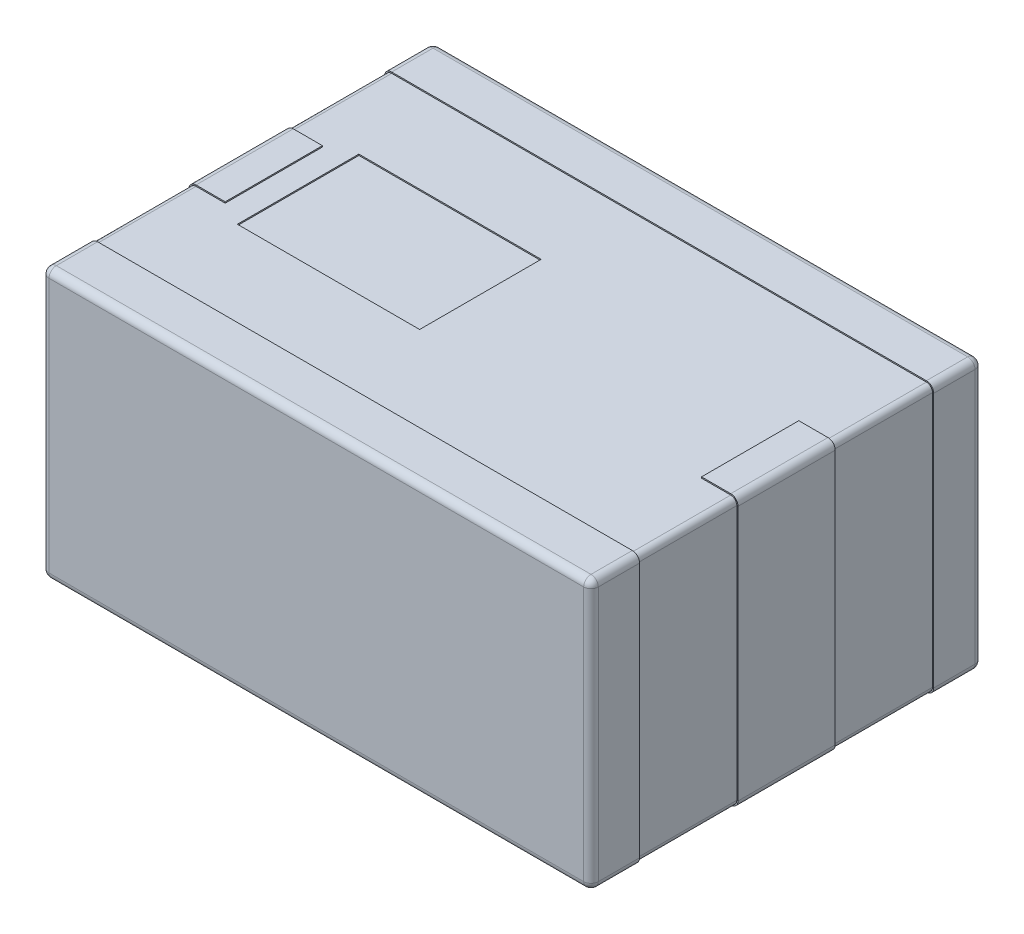
from build123d import *

# Parameters (mm, degrees)
SKETCH1_W           = 4.5
SKETCH1_H           = 3.2
BOSS_EXTRUDE1_DEPTH = 2.2
FILLET1_R           = 0.05
SKETCH2_W           = 0.3
SKETCH2_H           = 0.8
SKETCH2_W_2         = 4.52
SKETCH2_H_2         = 0.4
BOSS_EXTRUDE2_DEPTH = 0.01
SKETCH4_W           = 0.3
SKETCH4_H           = 0.8
SKETCH4_W_2         = 4.52
SKETCH4_H_2         = 0.4
BOSS_EXTRUDE3_DEPTH = 2.21
SKETCH3_W           = 1.5
SKETCH3_H           = 1
CUT_EXTRUDE1_DEPTH  = 0.01
FILLET2_R           = 0.06


with BuildPart() as part:
    # Sketch1 → Boss-Extrude1 (new body)
    with BuildSketch(Plane(origin=(0, 0, 0), x_dir=(1, 0, 0), z_dir=(0, 1, 0))):
        Rectangle(SKETCH1_W, SKETCH1_H)
    extrude(amount=BOSS_EXTRUDE1_DEPTH)

    # Fillet1
    fillet1_edges = [part.edges().sort_by_distance(p)[0] for p in [
        (-2.25, 2.2, 0),
        (0, 2.2, 1.6),
        (2.25, 2.2, 0),
        (0, 0, 1.6),
        (-2.25, 0, 0),
        (0, 0, -1.6),
        (2.25, 0, 0),
        (2.25, 1.1, 1.6),
        (-2.25, 1.1, 1.6),
        (-2.25, 1.1, -1.6),
        (2.25, 1.1, -1.6),
        (0, 2.2, -1.6),
    ]]
    fillet(fillet1_edges, radius=FILLET1_R)

    # Sketch2 → Boss-Extrude2 (add)
    with BuildSketch(Plane.XZ):
        with Locations((-2.11, 0)):
            Rectangle(SKETCH2_W, SKETCH2_H)
        with Locations((2.11, 0)):
            Rectangle(SKETCH2_W, SKETCH2_H)
        with Locations((0, 1.41)):
            Rectangle(SKETCH2_W_2, SKETCH2_H_2)
        with Locations((0, -1.41)):
            Rectangle(SKETCH2_W_2, SKETCH2_H_2)
    extrude(amount=BOSS_EXTRUDE2_DEPTH)

    # Sketch4 → Boss-Extrude3 (add)
    with BuildSketch(Plane.XZ):
        with Locations((-2.11, 0)):
            Rectangle(SKETCH4_W, SKETCH4_H)
        with Locations((0, 1.41)):
            Rectangle(SKETCH4_W_2, SKETCH4_H_2)
        with Locations((2.11, 0)):
            Rectangle(SKETCH4_W, SKETCH4_H)
        with Locations((0, -1.41)):
            Rectangle(SKETCH4_W_2, SKETCH4_H_2)
    extrude(amount=-BOSS_EXTRUDE3_DEPTH)

    # Sketch3 → Cut-Extrude1 (cut)
    with BuildSketch(Plane(origin=(0, 2.2, 0), x_dir=(1, 0, 0), z_dir=(0, 1, 0))):
        with Locations((-1.01, 0)):
            Rectangle(SKETCH3_W, SKETCH3_H)
    extrude(amount=-CUT_EXTRUDE1_DEPTH, mode=Mode.SUBTRACT)

    # Fillet2
    fillet2_edges = [part.edges().sort_by_distance(p)[0] for p in [
        (-2.26, 2.21, 0),
        (-2.26, 2.21, 1.41),
        (0, 2.21, 1.61),
        (2.26, 2.21, 1.41),
        (2.26, 2.21, 0),
        (0, 2.21, -1.61),
        (-2.26, 2.21, -1.41),
        (2.26, 2.21, -1.41),
        (-2.26, -0.01, 0),
        (2.26, -0.01, 0),
        (-2.26, 1.1, 1.61),
        (2.26, 1.1, 1.61),
        (-2.26, -0.01, 1.41),
        (2.26, -0.01, 1.41),
        (0, -0.01, 1.61),
        (-2.26, 1.1, -1.61),
        (2.26, 1.1, -1.61),
        (0, -0.01, -1.61),
        (2.26, -0.01, -1.41),
        (-2.26, -0.01, -1.41),
    ]]
    fillet(fillet2_edges, radius=FILLET2_R)


solid = part.part
